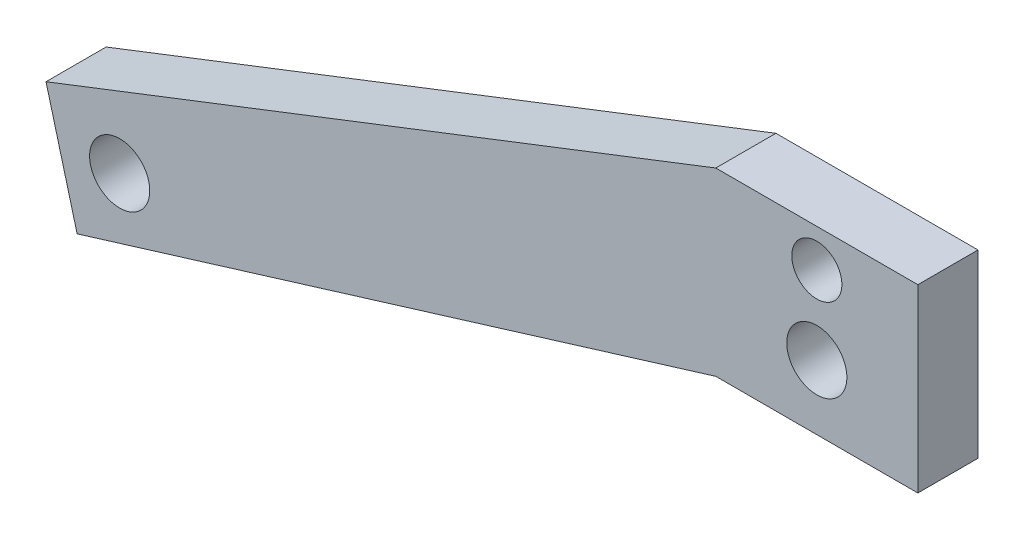
from build123d import *

# Parameters (mm, degrees)
SKETCH1_R           = 3.96875
SKETCH1_R_2         = 4.762500004
BOSS_EXTRUDE1_DEPTH = 9.525


with BuildPart() as part:
    # Sketch1 → Boss-Extrude1 (new body)
    with BuildSketch(Plane.XY):
        Polygon((-15.999994625, 44.999976622), (-122.071011472, 3.799748897), (-117.140508663, -14.601138094), (-15.999994625, 16.424976622), (16.000005375, 16.424976622), (16.000005375, 44.999976622), align=None)
        with Locations((5.375e-06, 38.999976622)):
            Circle(SKETCH1_R, mode=Mode.SUBTRACT)
        with Locations((5.373e-06, 26.647573661)):
            Circle(SKETCH1_R_2, mode=Mode.SUBTRACT)
        with Locations((-110.405316572, -2.935443194)):
            Circle(SKETCH1_R_2, mode=Mode.SUBTRACT)
    extrude(amount=BOSS_EXTRUDE1_DEPTH)


solid = part.part
